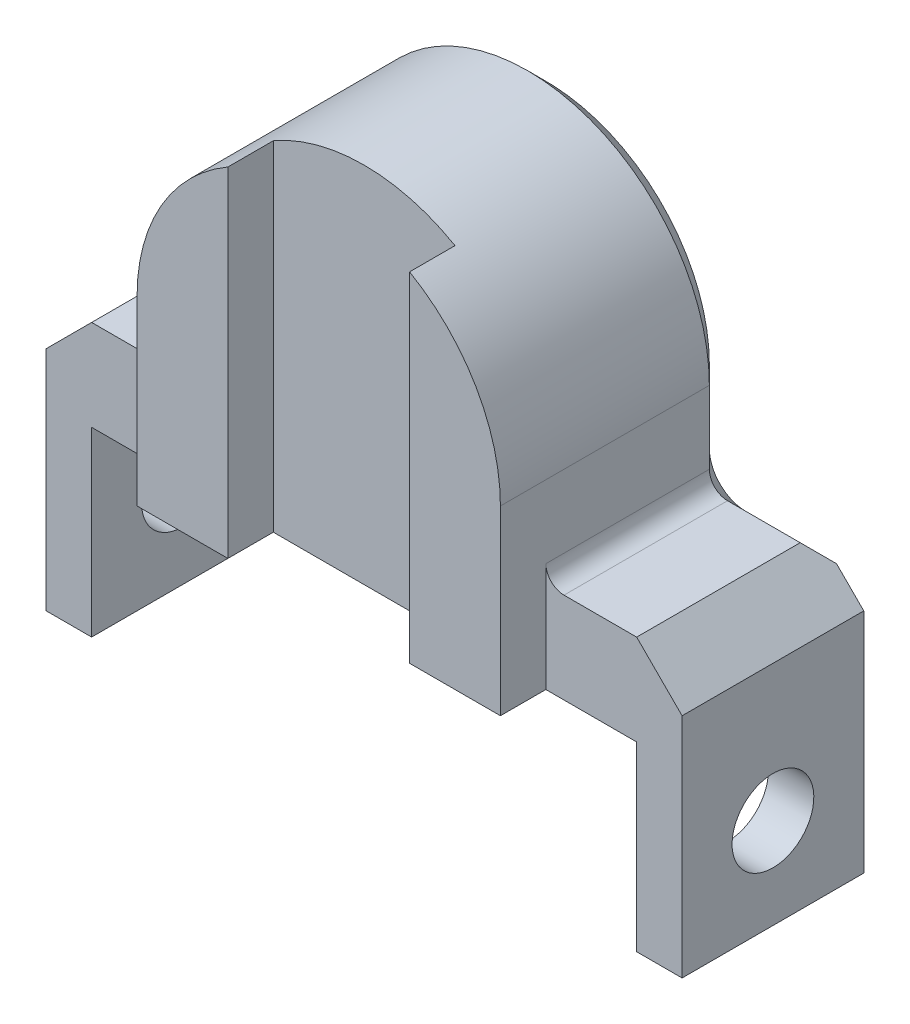
from build123d import *

# Parameters (mm, degrees)
EXTRUDE_1_DEPTH     = 10
SKETCH_2_R          = 4.5
CUT_EXTRUDE_1_DEPTH = 71
CHAMFER_3_SIZE      = 5
FILLET_2_R          = 2
CHAMFER_5_SIZE      = 2
EXTRUDE_2_DEPTH     = 5


with BuildPart() as part:
    # 草图1 → 凸台-拉伸1 (new body, symmetric)
    with BuildSketch(Plane.XY):
        with BuildLine():
            Line((-30, 0), (30, 0))
            Line((30, 0), (30, -20))
            Line((30, -20), (35, -20))
            Line((35, -20), (35, 10))
            Line((35, 10), (20, 10))
            Line((20, 10), (20, 20))
            ThreePointArc((20, 20), (0, 40), (-20, 20))
            Line((-20, 20), (-20, 10))
            Line((-20, 10), (-35, 10))
            Line((-35, 10), (-35, -20))
            Line((-35, -20), (-30, -20))
            Line((-30, -20), (-30, 0))
        make_face()
    extrude(amount=EXTRUDE_1_DEPTH, both=True)

    # 草图2 → 切除-拉伸1 (cut, through all)
    with BuildSketch(Plane.ZY.offset(35)):
        with Locations((0, -10)):
            Circle(SKETCH_2_R)
    extrude(amount=-CUT_EXTRUDE_1_DEPTH, mode=Mode.SUBTRACT)

    # 倒角3
    chamfer_3_edges = [part.edges().sort_by_distance(p)[0] for p in [
        (35, 10, 0),
        (-35, 10, 0),
    ]]
    chamfer(chamfer_3_edges, length=CHAMFER_3_SIZE)

    # 圆角2
    fillet_2_edges = [part.edges().sort_by_distance(p)[0] for p in [
        (-20, 10, 0),
        (20, 10, 0),
    ]]
    fillet(fillet_2_edges, radius=FILLET_2_R)

    # 倒角5
    chamfer_5_edges = [part.edges().sort_by_distance(p)[0] for p in [
        (-20, 16, -10),
        (0, 40, -10),
        (26, 10, -10),
        (-26, 10, -10),
        (20, 16, -10),
        (-20.585786438, 10.585786438, -10),
        (20.585786438, 10.585786438, -10),
    ]]
    chamfer(chamfer_5_edges, length=CHAMFER_5_SIZE)

    # 草图3 → 凸台-拉伸2 (add)
    with BuildSketch(Plane.XY.offset(10)):
        with BuildLine():
            Line((20, 0), (10, 0))
            Line((10, 0), (10, 37.320508076))
            ThreePointArc((10, 37.320508076), (17.320508076, 30), (20, 20))
            Line((20, 20), (20, 0))
        make_face()
        with BuildLine():
            Line((-10, 0), (-10, 37.320508076))
            ThreePointArc((-10, 37.320508076), (-17.320508076, 30), (-20, 20))
            Line((-20, 20), (-20, 0))
            Line((-20, 0), (-10, 0))
        make_face()
    extrude(amount=EXTRUDE_2_DEPTH)


solid = part.part
